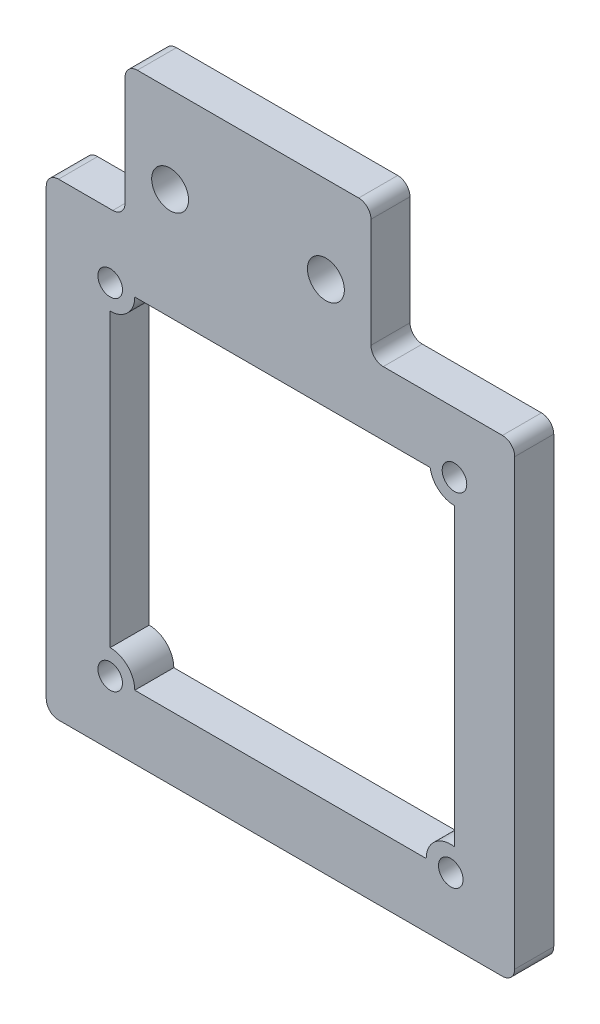
from build123d import *

# Parameters (mm, degrees)
SKETCH1_R           = 1
SKETCH1_R_2         = 1.5
BOSS_EXTRUDE1_DEPTH = 3.175
FILLET1_R           = 1


with BuildPart() as part:
    # Sketch1 → Boss-Extrude1 (new body)
    with BuildSketch(Plane.XY):
        Polygon((31.690894529, -38.1), (31.690894529, 0), (20, 0), (20, 10.87553853), (0, 10.87553853), (0, 0), (-6.409105471, 0), (-6.409105471, -38.1), align=None)
        with Locations((26.490894529, -32.9)):
            Circle(SKETCH1_R, mode=Mode.SUBTRACT)
        with Locations((-1.209105471, -32.9)):
            Circle(SKETCH1_R, mode=Mode.SUBTRACT)
        with Locations((-1.209105471, -5.2)):
            Circle(SKETCH1_R, mode=Mode.SUBTRACT)
        with Locations((26.790894529, -4.9)):
            Circle(SKETCH1_R, mode=Mode.SUBTRACT)
        with Locations((16.335044769, 3.811593223)):
            Circle(SKETCH1_R_2, mode=Mode.SUBTRACT)
        with Locations((3.664955231, 3.811593223)):
            Circle(SKETCH1_R_2, mode=Mode.SUBTRACT)
        with BuildLine():
            Line((26.790894529, -6.9), (26.790894529, -30.922628007))
            ThreePointArc((26.790894529, -30.922628007), (25.187054048, -31.383424911), (24.490894529, -32.9))
            Line((24.490894529, -32.9), (0.790894529, -32.9))
            ThreePointArc((0.790894529, -32.9), (0.205108092, -31.485786438), (-1.209105471, -30.9))
            Line((-1.209105471, -30.9), (-1.209105471, -7.2))
            ThreePointArc((-1.209105471, -7.2), (0.205108092, -6.614213562), (0.790894529, -5.2))
            Line((0.790894529, -5.2), (24.813522536, -5.2))
            ThreePointArc((24.813522536, -5.2), (25.487054048, -6.416575089), (26.790894529, -6.9))
        make_face(mode=Mode.SUBTRACT)
    extrude(amount=BOSS_EXTRUDE1_DEPTH)

    # Fillet1
    fillet1_edges = [part.edges().sort_by_distance(p)[0] for p in [
        (20, 10.87553853, 1.5875),
        (20, 0, 1.5875),
        (31.690894529, 0, 1.5875),
        (31.690894529, -38.1, 1.5875),
        (-6.409105471, -38.1, 1.5875),
        (-6.409105471, 0, 1.5875),
        (0, 0, 1.5875),
        (0, 10.87553853, 1.5875),
    ]]
    fillet(fillet1_edges, radius=FILLET1_R)


solid = part.part
